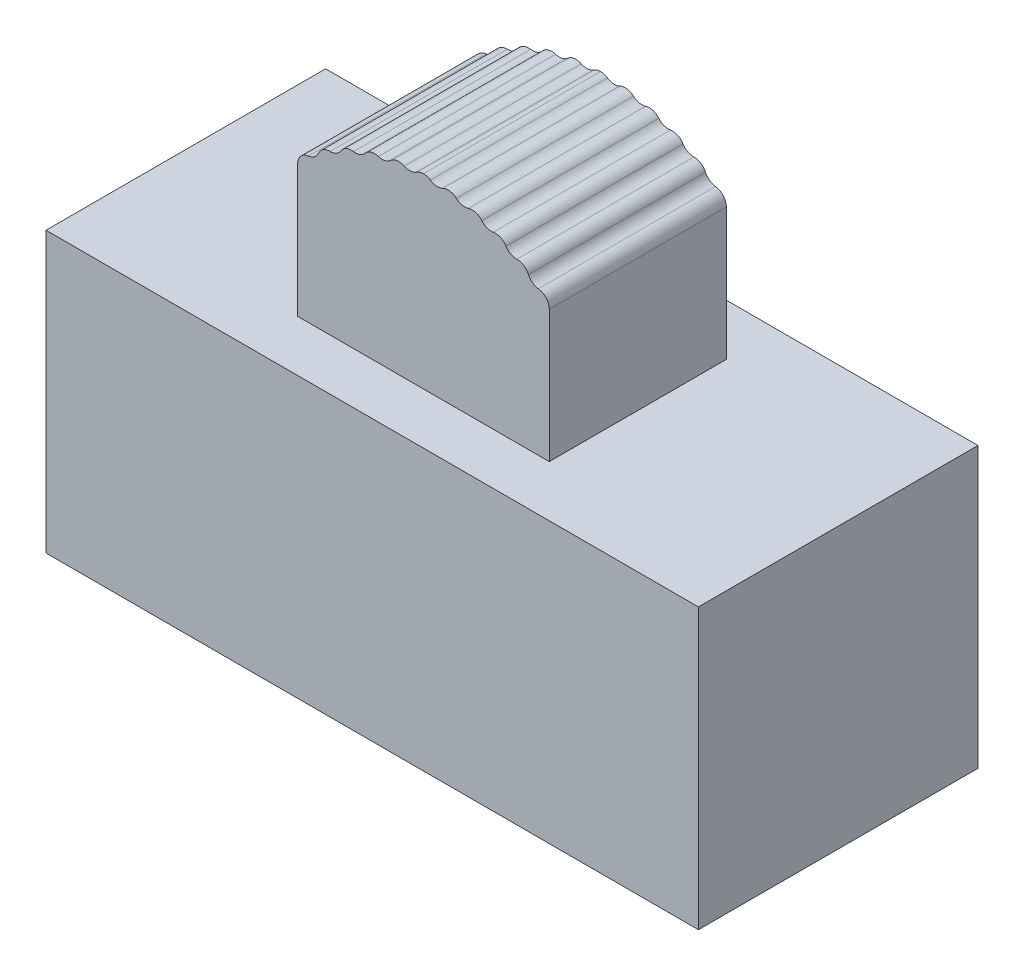
from build123d import *

# Parameters (mm, degrees)
SKETCH1_W           = 14
SKETCH1_H           = 6
BOSS_EXTRUDE1_DEPTH = 6
SKETCH2_W           = 5.4
SKETCH2_H           = 3.8
BOSS_EXTRUDE2_DEPTH = 4
CUT_EXTRUDE1_DEPTH  = 5.9


with BuildPart() as part:
    # Sketch1 → Boss-Extrude1 (new body)
    with BuildSketch(Plane(origin=(0, 0, 0), x_dir=(1, 0, 0), z_dir=(0, 1, 0))):
        Rectangle(SKETCH1_W, SKETCH1_H)
    extrude(amount=BOSS_EXTRUDE1_DEPTH)

    # Sketch2 → Boss-Extrude2 (add)
    with BuildSketch(Plane(origin=(0, 6, 0), x_dir=(1, 0, 0), z_dir=(0, 1, 0))):
        Rectangle(SKETCH2_W, SKETCH2_H)
    extrude(amount=BOSS_EXTRUDE2_DEPTH)

    # Sketch3 → Cut-Extrude1 (cut, through all)
    with BuildSketch(Plane.XY.offset(1.9)):
        with BuildLine():
            Line((-2.7, 10), (-2.7, 8.832137002))
            ThreePointArc((-2.7, 8.832137002), (-2.632889163, 9.008389319), (-2.465548082, 9.095370387))
            ThreePointArc((-2.465548082, 9.095370387), (-2.338024057, 9.145911014), (-2.252855325, 9.253442494))
            ThreePointArc((-2.252855325, 9.253442494), (-2.152197575, 9.371653244), (-2.002596083, 9.413188261))
            ThreePointArc((-2.002596083, 9.413188261), (-1.869202273, 9.445169874), (-1.769670652, 9.539563668))
            ThreePointArc((-1.769670652, 9.539563668), (-1.653294376, 9.642336847), (-1.499320058, 9.662278599))
            ThreePointArc((-1.499320058, 9.662278599), (-1.362742465, 9.67505722), (-1.250852111, 9.754412627))
            ThreePointArc((-1.250852111, 9.754412627), (-1.121100646, 9.839678807), (-0.96585391, 9.83762575))
            ThreePointArc((-0.96585391, 9.83762575), (-0.828842644, 9.83094407), (-0.706846566, 9.893663199))
            ThreePointArc((-0.706846566, 9.893663199), (-0.566332573, 9.959705471), (-0.412939448, 9.935698945))
            ThreePointArc((-0.412939448, 9.935698945), (-0.27825335, 9.909691506), (-0.148608047, 9.954511452))
            ThreePointArc((-0.148608047, 9.954511452), (-0.077790585, 9.98837122), (-0.000160897, 9.999999997))
            Line((-0.000160897, 10), (-2.7, 10))
        make_face()
        with BuildLine():
            Line((2.7, 10), (0.000160897, 10))
            ThreePointArc((0.000160897, 9.999999997), (0.077790585, 9.98837122), (0.148608047, 9.954511452))
            ThreePointArc((0.148608047, 9.954511452), (0.27825335, 9.909691506), (0.412939448, 9.935698945))
            ThreePointArc((0.412939448, 9.935698945), (0.566332573, 9.959705471), (0.706846566, 9.893663199))
            ThreePointArc((0.706846566, 9.893663199), (0.828842644, 9.83094407), (0.96585391, 9.83762575))
            ThreePointArc((0.96585391, 9.83762575), (1.121100646, 9.839678807), (1.250852111, 9.754412627))
            ThreePointArc((1.250852111, 9.754412627), (1.362742465, 9.67505722), (1.499320058, 9.662278599))
            ThreePointArc((1.499320058, 9.662278599), (1.653294376, 9.642336847), (1.769670652, 9.539563668))
            ThreePointArc((1.769670652, 9.539563668), (1.869202273, 9.445169874), (2.002596083, 9.413188261))
            ThreePointArc((2.002596083, 9.413188261), (2.152197575, 9.371653244), (2.252855325, 9.253442494))
            ThreePointArc((2.252855325, 9.253442494), (2.338024057, 9.145911014), (2.465548082, 9.095370387))
            ThreePointArc((2.465548082, 9.095370387), (2.632889163, 9.008389319), (2.7, 8.832137002))
            Line((2.7, 8.832137002), (2.7, 10))
        make_face()
    extrude(amount=-CUT_EXTRUDE1_DEPTH, mode=Mode.SUBTRACT)


solid = part.part
